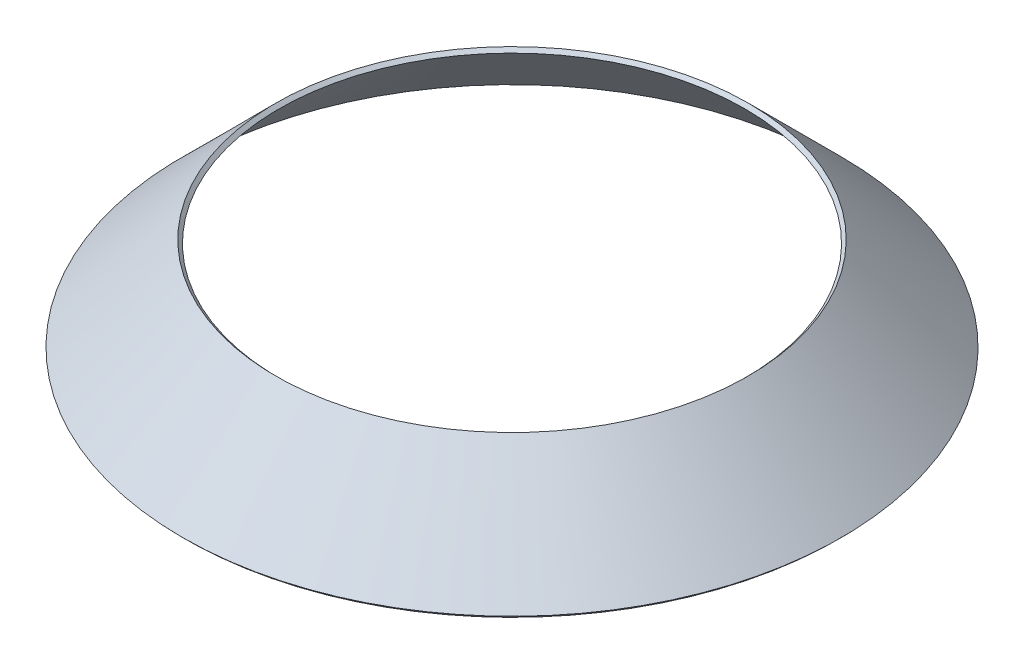
from build123d import *


with BuildPart() as part:
    # 草图1 → 旋转1 (revolve)
    with BuildSketch(Plane(origin=(0, 0, 0), x_dir=(0, 0, -1), z_dir=(1, 0, 0))):
        Polygon((5, 0.986733793), (7, -1.013266207), (7.070710678, -0.942555529), (5.070710678, 1.057444471), align=None)
    revolve(axis=Axis((0, 0, 0), (0, 1, 0)))


solid = part.part
